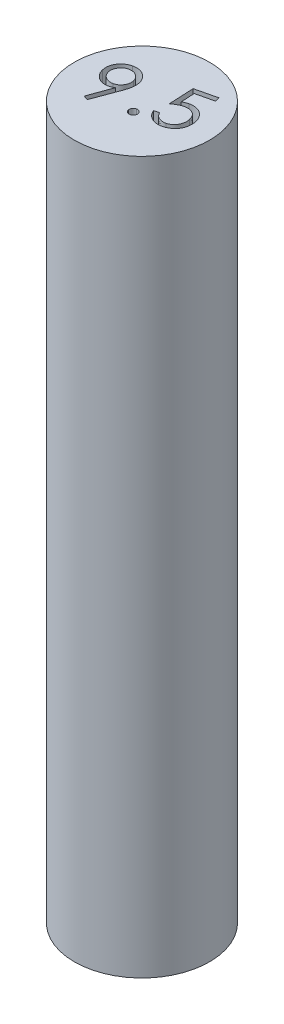
from build123d import *

# Parameters (mm, degrees)
SKETCH1_R           = 4.75
BOSS_EXTRUDE1_DEPTH = 50
CUT_EXTRUDE1_DEPTH  = 3


with BuildPart() as part:
    # Sketch1 → Boss-Extrude1 (new body)
    with BuildSketch(Plane(origin=(0, 0, 0), x_dir=(1, 0, 0), z_dir=(0, 1, 0))):
        Circle(SKETCH1_R)
    extrude(amount=BOSS_EXTRUDE1_DEPTH)

    # Sketch2 → Cut-Extrude1 (cut)
    with BuildSketch(Plane(origin=(0, 50, 0), x_dir=(1, 0, 0), z_dir=(0, 1, 0))):
        with BuildLine():
            Line((-2.017000607, -1.829259681), (-2.338114389, -1.71567795))
            Line((-2.338114389, -1.71567795), (-1.755482177, -0.113614649))
            add(Edge.make_bspline(
                [(-1.755482177, -0.113614649), (-1.783270788, -0.129992136), (-1.83755668, -0.161986051), (-1.921397106, -0.200722075), (-2.003489552, -0.233425169), (-2.059129351, -0.248063513), (-2.086411665, -0.255241251)],
                knots=[0, 0, 0, 0, 9.6704e-05, 0.000188914, 0.000276804, 0.000361361, 0.000361361, 0.000361361, 0.000361361], degree=3))
            add(Edge.make_bspline(
                [(-2.086411665, -0.255241251), (-2.119488943, -0.262228742), (-2.184741454, -0.276013169), (-2.283465656, -0.284732795), (-2.380511151, -0.284510491), (-2.475908308, -0.272933284), (-2.569644856, -0.251810975), (-2.6617379, -0.220811828), (-2.752240176, -0.179816146), (-2.839453739, -0.128781878), (-2.922845702, -0.07057329), (-2.998442619, -0.004255985), (-3.067377142, 0.067528061), (-3.127451279, 0.146413128), (-3.180523666, 0.231018356), (-3.225531903, 0.322157108), (-3.262862923, 0.41960496), (-3.281030105, 0.487759845), (-3.290237786, 0.522302819)],
                knots=[0, 0, 0, 0, 0.000101343, 0.000199922, 0.00029668, 0.000391994, 0.000487586, 0.000584475, 0.000683002, 0.000785099, 0.000887225, 0.00098761, 0.001086299, 0.001185304, 0.001284519, 0.001385483, 0.001489783, 0.001596972, 0.001596972, 0.001596972, 0.001596972], degree=3))
            add(Edge.make_bspline(
                [(-3.290237786, 0.522302819), (-3.29989586, 0.570267614), (-3.318848383, 0.664391347), (-3.325626608, 0.806930059), (-3.313605961, 0.946241013), (-3.283456708, 1.081902376), (-3.235347926, 1.211969135), (-3.168082295, 1.333462958), (-3.08584721, 1.447592554), (-2.985973578, 1.550451829), (-2.874346702, 1.641995332), (-2.751777139, 1.717314104), (-2.621373665, 1.777793118), (-2.529028992, 1.803122491), (-2.482545479, 1.815872531)],
                knots=[0, 0, 0, 0, 0.00014662, 0.00028772, 0.000426354, 0.000564988, 0.000703424, 0.000840851, 0.00098039, 0.001124194, 0.00126972, 0.001412339, 0.001554791, 0.001699176, 0.001699176, 0.001699176, 0.001699176], degree=3))
            add(Edge.make_bspline(
                [(-2.482545479, 1.815872531), (-2.435982585, 1.825303792), (-2.344194688, 1.843895326), (-2.204163861, 1.849865151), (-2.066130485, 1.836913074), (-1.93054663, 1.806854933), (-1.800235703, 1.759369088), (-1.677900059, 1.694694921), (-1.566155236, 1.611988038), (-1.465249364, 1.514831188), (-1.37615744, 1.406118089), (-1.303222988, 1.287224806), (-1.243830464, 1.161069532), (-1.219469229, 1.071501206), (-1.207204934, 1.02640939)],
                knots=[0, 0, 0, 0, 0.000142355, 0.00028062, 0.000418619, 0.000557253, 0.000696103, 0.000833482, 0.000970909, 0.001111739, 0.001252776, 0.001391307, 0.00152935, 0.001669302, 0.001669302, 0.001669302, 0.001669302], degree=3))
            add(Edge.make_bspline(
                [(-1.207204934, 1.02640939), (-1.200043221, 0.990754997), (-1.185482183, 0.918263258), (-1.174941336, 0.805541243), (-1.17659176, 0.688045513), (-1.186118478, 0.56371164), (-1.20881103, 0.429432811), (-1.244689867, 0.28134551), (-1.293811599, 0.117815059), (-1.334484581, 0.0046859), (-1.355842754, -0.054720418)],
                knots=[0, 0, 0, 0, 0.000109053, 0.000221725, 0.000338814, 0.000461203, 0.000595486, 0.000746838, 0.000918084, 0.001107446, 0.001107446, 0.001107446, 0.001107446], degree=3))
            Line((-1.355842754, -0.054720418), (-2.017000607, -1.829259681))
        make_face()
        with BuildLine():
            add(Edge.make_bspline(
                [(-2.077998203, 0.060263556), (-2.053752852, 0.06649752), (-2.006113509, 0.078746546), (-1.938354705, 0.106284651), (-1.874486234, 0.138131824), (-1.814921963, 0.176344954), (-1.76022137, 0.220841943), (-1.709424911, 0.270601871), (-1.663671792, 0.326893884), (-1.621868327, 0.38760035), (-1.586840101, 0.45258903), (-1.556571139, 0.518510899), (-1.535043328, 0.586382773), (-1.519903406, 0.655127888), (-1.51337028, 0.725235936), (-1.512266287, 0.796356533), (-1.519350686, 0.868749909), (-1.529496994, 0.916647034), (-1.534628812, 0.940872531)],
                knots=[0, 0, 0, 0, 7.5023e-05, 0.000147412, 0.000218903, 0.000288917, 0.000359214, 0.000430111, 0.000501838, 0.000576513, 0.000650878, 0.000723063, 0.000793793, 0.000864063, 0.000933827, 0.001004644, 0.001077199, 0.001151452, 0.001151452, 0.001151452, 0.001151452], degree=3))
            add(Edge.make_bspline(
                [(-1.534628812, 0.940872531), (-1.540896903, 0.964871648), (-1.553267865, 1.012237291), (-1.580441133, 1.079688058), (-1.612743532, 1.143080166), (-1.650455747, 1.202512195), (-1.695464393, 1.256572368), (-1.744931529, 1.307371008), (-1.801269556, 1.353086298), (-1.861961255, 1.394906393), (-1.926960984, 1.429907675), (-1.993056946, 1.460357775), (-2.061257075, 1.48159535), (-2.130187593, 1.496886866), (-2.200536906, 1.503406524), (-2.271892183, 1.504525521), (-2.344739041, 1.497356303), (-2.392880828, 1.487265556), (-2.417341152, 1.482138556)],
                knots=[0, 0, 0, 0, 7.4349e-05, 0.000146738, 0.000217603, 0.000287617, 0.000357371, 0.000428267, 0.000499994, 0.00057467, 0.000649035, 0.00072122, 0.000792617, 0.000862887, 0.000932651, 0.001004169, 0.001076724, 0.001151665, 0.001151665, 0.001151665, 0.001151665], degree=3))
            add(Edge.make_bspline(
                [(-2.417341152, 1.482138556), (-2.441345708, 1.475878595), (-2.488722084, 1.463523679), (-2.556094524, 1.436233318), (-2.619714559, 1.404393143), (-2.67818654, 1.365042903), (-2.733063603, 1.320932324), (-2.783797396, 1.271079118), (-2.829569422, 1.214812994), (-2.871360887, 1.154098052), (-2.906417248, 1.089116256), (-2.936589259, 1.023176027), (-2.958382515, 0.955633208), (-2.97222658, 0.886908253), (-2.980172177, 0.817228724), (-2.980885202, 0.74603515), (-2.973907225, 0.673654909), (-2.963746359, 0.625755987), (-2.958607177, 0.601529582)],
                knots=[0, 0, 0, 0, 7.4349e-05, 0.000146738, 0.000217603, 0.000287413, 0.000357711, 0.000428607, 0.000500334, 0.00057501, 0.000649375, 0.00072156, 0.00079229, 0.000861729, 0.000931567, 0.001002384, 0.001074939, 0.001149192, 0.001149192, 0.001149192, 0.001149192], degree=3))
            add(Edge.make_bspline(
                [(-2.958607177, 0.601529582), (-2.95234022, 0.577529481), (-2.939971496, 0.530161898), (-2.912781897, 0.462725292), (-2.880539716, 0.399280966), (-2.842508331, 0.339887731), (-2.798290779, 0.285117341), (-2.747784143, 0.235125324), (-2.692264536, 0.188497611), (-2.631224636, 0.146860651), (-2.566297802, 0.111734511), (-2.500340473, 0.081600719), (-2.432594054, 0.059653949), (-2.363592601, 0.046093512), (-2.293702926, 0.037730471), (-2.222500441, 0.038252222), (-2.150124094, 0.044894352), (-2.102224798, 0.055101145), (-2.077998203, 0.060263556)],
                knots=[0, 0, 0, 0, 7.4349e-05, 0.000146738, 0.000217603, 0.000287617, 0.000357915, 0.000428314, 0.000500488, 0.000575164, 0.000649529, 0.000721714, 0.000792444, 0.00086257, 0.000932408, 0.001003221, 0.001075776, 0.001150029, 0.001150029, 0.001150029, 0.001150029], degree=3))
        make_face(mode=Mode.SUBTRACT)
        with BuildLine():
            add(Edge.make_bspline(
                [(0.270129628, -0.661742134), (0.28944905, -0.658152163), (0.327221006, -0.65113331), (0.384713886, -0.654090109), (0.439707514, -0.669367918), (0.491266669, -0.695288597), (0.537097075, -0.730232115), (0.576504182, -0.772079705), (0.604729034, -0.822894951), (0.615772195, -0.860138195), (0.621391647, -0.87908989)],
                knots=[0, 0, 0, 0, 5.8798e-05, 0.000114958, 0.000170916, 0.000228923, 0.000286977, 0.000343053, 0.000400189, 0.000459387, 0.000459387, 0.000459387, 0.000459387], degree=3))
            add(Edge.make_bspline(
                [(0.621391647, -0.87908989), (0.624981048, -0.89817658), (0.632039727, -0.9357112), (0.628977073, -0.993191219), (0.613679351, -1.048847293), (0.587908212, -1.101151712), (0.553907917, -1.148624888), (0.511219945, -1.18684122), (0.461614212, -1.216044022), (0.424915803, -1.226902142), (0.406147256, -1.232455275)],
                knots=[0, 0, 0, 0, 5.8104e-05, 0.000114264, 0.000170899, 0.000230163, 0.000288361, 0.000344957, 0.000400875, 0.000459409, 0.000459409, 0.000459409, 0.000459409], degree=3))
            add(Edge.make_bspline(
                [(0.406147256, -1.232455275), (0.387049317, -1.23582258), (0.349448625, -1.242452248), (0.292279994, -1.23852904), (0.237123352, -1.223301372), (0.184975645, -1.197726366), (0.139068253, -1.162055475), (0.101170249, -1.119332932), (0.071984579, -1.069876204), (0.061135081, -1.033175908), (0.055586358, -1.014406396)],
                knots=[0, 0, 0, 0, 5.8007e-05, 0.000114206, 0.000170164, 0.000228799, 0.000287279, 0.000343408, 0.000399327, 0.000457861, 0.000457861, 0.000457861, 0.000457861], degree=3))
            add(Edge.make_bspline(
                [(0.055586358, -1.014406396), (0.051981989, -0.994847902), (0.044932718, -0.956596233), (0.048082839, -0.898769388), (0.062403876, -0.843113218), (0.088546774, -0.791298306), (0.122865747, -0.74459724), (0.165324543, -0.706499027), (0.214551239, -0.677332985), (0.251346592, -0.667011151), (0.270129628, -0.661742134)],
                knots=[0, 0, 0, 0, 5.9492e-05, 0.000116352, 0.00017213, 0.000230765, 0.000289379, 0.000344984, 0.000400903, 0.000459214, 0.000459214, 0.000459214, 0.000459214], degree=3))
        make_face()
        with BuildLine():
            Line((2.49762904, 2.909496608), (2.574051316, 2.586980582))
            Line((2.574051316, 2.586980582), (1.36882295, 2.300221768))
            Line((1.36882295, 2.300221768), (1.420705963, 1.338282666))
            add(Edge.make_bspline(
                [(1.420705963, 1.338282666), (1.454180938, 1.356388201), (1.519116343, 1.391509669), (1.616316061, 1.436862442), (1.710779948, 1.471532717), (1.773243058, 1.488508268), (1.803518463, 1.496736191)],
                knots=[0, 0, 0, 0, 0.00011416, 0.00022145, 0.000321485, 0.000415576, 0.000415576, 0.000415576, 0.000415576], degree=3))
            add(Edge.make_bspline(
                [(1.803518463, 1.496736191), (1.841483631, 1.504967379), (1.915972166, 1.521117158), (2.02808659, 1.532123283), (2.137273406, 1.532200035), (2.243694563, 1.52171628), (2.347615811, 1.500613143), (2.448810617, 1.468406354), (2.546755561, 1.424295579), (2.64095934, 1.370609689), (2.729781099, 1.307723337), (2.811529123, 1.236564448), (2.885523486, 1.157818671), (2.951066313, 1.071068472), (3.007928815, 0.976390945), (3.057160591, 0.874388213), (3.098062585, 0.764460209), (3.118306587, 0.687604295), (3.128638655, 0.64837882)],
                knots=[0, 0, 0, 0, 0.000116464, 0.000228506, 0.00033718, 0.00044357, 0.000548759, 0.000654747, 0.000761458, 0.000870423, 0.000979558, 0.001087396, 0.001195034, 0.001303147, 0.001412928, 0.001525818, 0.001642508, 0.001764144, 0.001764144, 0.001764144, 0.001764144], degree=3))
            add(Edge.make_bspline(
                [(3.128638655, 0.64837882), (3.139921338, 0.593432253), (3.162185496, 0.485005996), (3.169813441, 0.320076356), (3.157526294, 0.157464892), (3.128885428, 0.025086039), (3.097589916, -0.077801482), (3.068446305, -0.151614355), (3.035700176, -0.222466219), (2.99843661, -0.289938258), (2.956842166, -0.354211226), (2.910631437, -0.415114146), (2.859755414, -0.472711801), (2.805428143, -0.5275783), (2.746131481, -0.577857801), (2.683844379, -0.625008759), (2.617619343, -0.668040877), (2.54759553, -0.706295182), (2.474061029, -0.740905043), (2.396892471, -0.771826337), (2.315823482, -0.798410957), (2.260037756, -0.81260957), (2.23190388, -0.819770219)],
                knots=[0, 0, 0, 0, 0.000168065, 0.000331643, 0.000493394, 0.000656067, 0.000736791, 0.000815822, 0.000893927, 0.000970811, 0.00104685, 0.001123413, 0.001199922, 0.001277262, 0.00135483, 0.001432936, 0.001511502, 0.001591519, 0.001672124, 0.001755188, 0.001840771, 0.001927845, 0.001927845, 0.001927845, 0.001927845], degree=3))
            add(Edge.make_bspline(
                [(2.23190388, -0.819770219), (2.198124851, -0.827163919), (2.131475792, -0.841752354), (2.03119541, -0.852666526), (1.933131984, -0.854872596), (1.837421589, -0.848487168), (1.74354283, -0.834199444), (1.652179277, -0.809072995), (1.562760996, -0.776067435), (1.476168905, -0.734786085), (1.393511545, -0.686119136), (1.317142064, -0.629450053), (1.245783704, -0.567860906), (1.180852101, -0.499194204), (1.122113166, -0.424208667), (1.069160212, -0.342789553), (1.022013385, -0.255382522), (0.996239764, -0.193441662), (0.983205963, -0.162117975)],
                knots=[0, 0, 0, 0, 0.000103676, 0.000204562, 0.000302041, 0.000397602, 0.000492006, 0.000586398, 0.000681342, 0.000777621, 0.000873815, 0.000968612, 0.001062533, 0.001156266, 0.001251642, 0.001347903, 0.001447338, 0.001549069, 0.001549069, 0.001549069, 0.001549069], degree=3))
            Line((0.983205963, -0.162117975), (1.330962373, -0.079385604))
            add(Edge.make_bspline(
                [(1.330962373, -0.079385604), (1.345311165, -0.108929749), (1.373037271, -0.166017771), (1.423046695, -0.243305858), (1.477272836, -0.31019155), (1.536725956, -0.366666048), (1.602633113, -0.412248636), (1.673084584, -0.451824215), (1.751066571, -0.481292987), (1.833549643, -0.504522026), (1.919404805, -0.518482091), (2.005921085, -0.522644713), (2.092374575, -0.517461334), (2.148805472, -0.505886293), (2.17721638, -0.50005868)],
                knots=[0, 0, 0, 0, 9.846e-05, 0.000190253, 0.000275447, 0.000356295, 0.000435274, 0.000515291, 0.000598097, 0.000684679, 0.00077205, 0.00085839, 0.000944111, 0.001031028, 0.001031028, 0.001031028, 0.001031028], degree=3))
            add(Edge.make_bspline(
                [(2.17721638, -0.50005868), (2.204535568, -0.492994129), (2.258271567, -0.479098375), (2.334542455, -0.447265261), (2.406335382, -0.409568961), (2.47355167, -0.364444833), (2.535343686, -0.311464487), (2.592399349, -0.251542069), (2.644420752, -0.184533361), (2.691010503, -0.111248525), (2.731615808, -0.033322496), (2.763996094, 0.047917908), (2.787114091, 0.131696322), (2.80269147, 0.217097229), (2.809627756, 0.304928562), (2.808344345, 0.394634997), (2.797463717, 0.486566306), (2.784629932, 0.547737404), (2.778077758, 0.578967762)],
                knots=[0, 0, 0, 0, 8.4557e-05, 0.000166321, 0.000247239, 0.000327551, 0.000408618, 0.000490939, 0.000575368, 0.000662696, 0.000751127, 0.000838618, 0.000924525, 0.001011441, 0.001098663, 0.001188417, 0.001280168, 0.00137587, 0.00137587, 0.00137587, 0.00137587], degree=3))
            add(Edge.make_bspline(
                [(2.778077758, 0.578967762), (2.770919821, 0.606718636), (2.756883311, 0.661137312), (2.726714744, 0.738533598), (2.692149987, 0.810888836), (2.651062862, 0.877251213), (2.60465963, 0.938171707), (2.55173122, 0.99294241), (2.493217166, 1.042240249), (2.429669943, 1.085709473), (2.361536445, 1.121864327), (2.290486271, 1.152033021), (2.215711851, 1.172745783), (2.138206771, 1.186158225), (2.057865634, 1.19168265), (1.974577699, 1.18931729), (1.888199128, 1.179679535), (1.830305729, 1.167251397), (1.800713976, 1.160898852)],
                knots=[0, 0, 0, 0, 8.5907e-05, 0.000168461, 0.000248735, 0.000326177, 0.000402183, 0.00047805, 0.000554176, 0.000631379, 0.000708544, 0.000785236, 0.000862474, 0.000940739, 0.001020864, 0.001103623, 0.001190417, 0.001281169, 0.001281169, 0.001281169, 0.001281169], degree=3))
            add(Edge.make_bspline(
                [(1.800713976, 1.160898852), (1.775375429, 1.154217949), (1.723227451, 1.140468322), (1.644541545, 1.112724797), (1.563111951, 1.078212122), (1.479230079, 1.036736723), (1.392828059, 0.988744555), (1.303619584, 0.93464686), (1.211762794, 0.873821036), (1.151049554, 0.829071975), (1.119924713, 0.806131223)],
                knots=[0, 0, 0, 0, 7.8588e-05, 0.000161738, 0.000250027, 0.000343781, 0.00044232, 0.00054645, 0.000656707, 0.000772689, 0.000772689, 0.000772689, 0.000772689], degree=3))
            Line((1.119924713, 0.806131223), (1.032284489, 2.560337954))
            Line((1.032284489, 2.560337954), (2.49762904, 2.909496608))
        make_face()
    extrude(amount=-CUT_EXTRUDE1_DEPTH, mode=Mode.SUBTRACT)


solid = part.part
